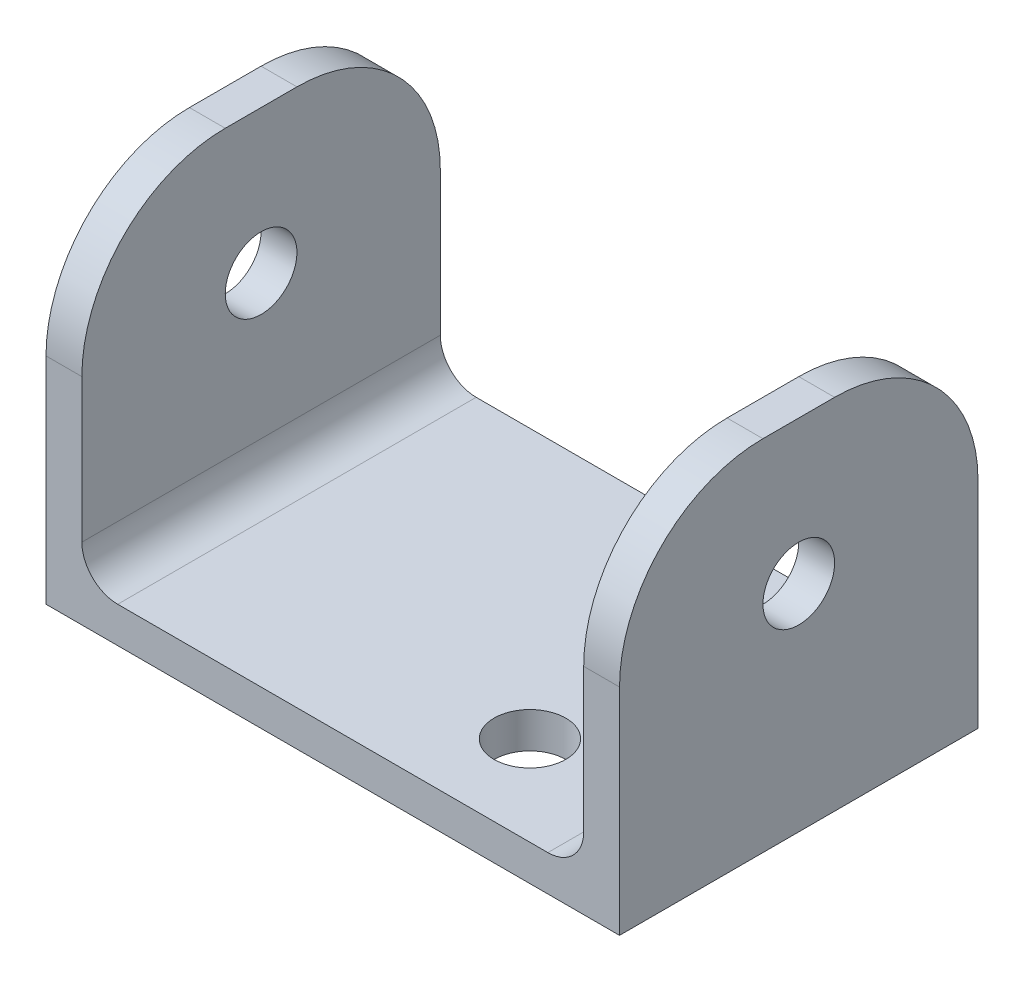
from build123d import *

# Parameters (mm, degrees)
SKETCH1_W           = 50.8
SKETCH1_H           = 31.75
BOSS_EXTRUDE1_DEPTH = 15.875
SKETCH2_W           = 44.45
SKETCH2_H           = 28.575
CUT_EXTRUDE1_DEPTH  = 32.75
SKETCH3_R           = 3.175
CUT_EXTRUDE2_DEPTH  = 4.175
FILLET1_R           = 3.175
SKETCH4_R           = 3.175
CUT_EXTRUDE3_DEPTH  = 51.8
FILLET2_R           = 12.7


with BuildPart() as part:
    # Sketch1 → Boss-Extrude1 (new body, symmetric)
    with BuildSketch(Plane.XY):
        Rectangle(SKETCH1_W, SKETCH1_H)
    extrude(amount=BOSS_EXTRUDE1_DEPTH, both=True)

    # Sketch2 → Cut-Extrude1 (cut, through all)
    with BuildSketch(Plane.XY.offset(15.875)):
        with Locations((0, 1.5875)):
            Rectangle(SKETCH2_W, SKETCH2_H)
    extrude(amount=-CUT_EXTRUDE1_DEPTH, mode=Mode.SUBTRACT)

    # Sketch3 → Cut-Extrude2 (cut, through all)
    with BuildSketch(Plane(origin=(0, -12.7, 0), x_dir=(1, 0, 0), z_dir=(0, 1, 0))):
        with Locations((9.525, 7.9375)):
            Circle(SKETCH3_R)
        with Locations((9.525, -7.9375)):
            Circle(SKETCH3_R)
    extrude(amount=-CUT_EXTRUDE2_DEPTH, mode=Mode.SUBTRACT)

    # Fillet1
    fillet1_edges = [part.edges().sort_by_distance(p)[0] for p in [
        (-22.225, -12.7, 0),
        (22.225, -12.7, 0),
    ]]
    fillet(fillet1_edges, radius=FILLET1_R)

    # Sketch4 → Cut-Extrude3 (cut, through all)
    with BuildSketch(Plane(origin=(25.4, 0, 0), x_dir=(0, 0, -1), z_dir=(1, 0, 0))):
        with Locations((0, 3.175)):
            Circle(SKETCH4_R)
    extrude(amount=-CUT_EXTRUDE3_DEPTH, mode=Mode.SUBTRACT)

    # Fillet2
    fillet2_edges = [part.edges().sort_by_distance(p)[0] for p in [
        (-23.8125, 15.875, -15.875),
        (-23.8125, 15.875, 15.875),
        (23.8125, 15.875, -15.875),
        (23.8125, 15.875, 15.875),
    ]]
    fillet(fillet2_edges, radius=FILLET2_R)


solid = part.part
